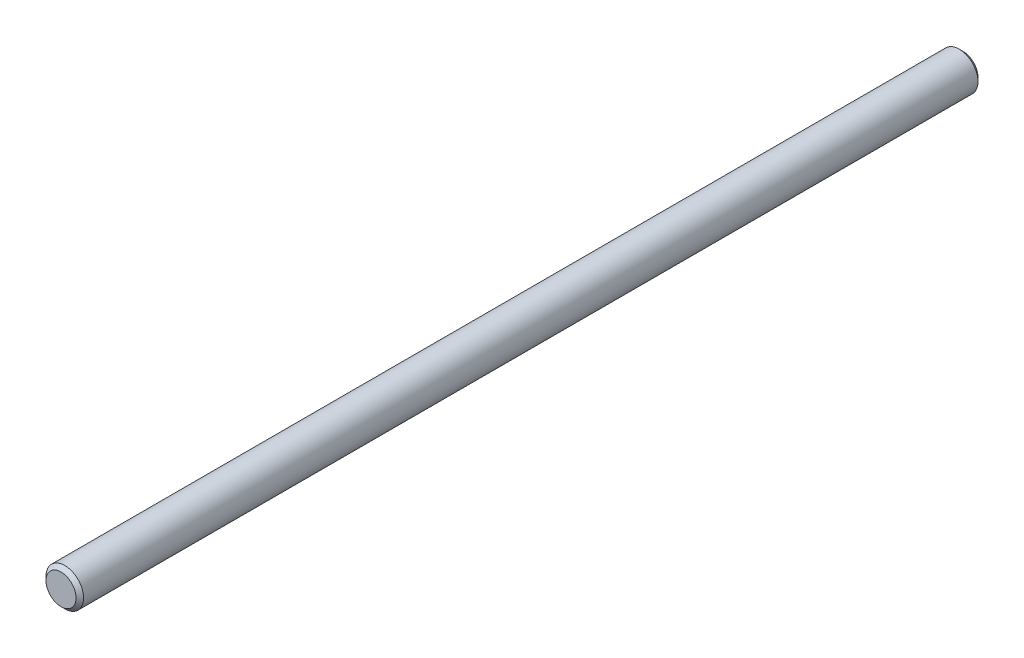
from build123d import *

# Parameters (mm, degrees)
SKETCH1_R      = 6.35
EXTRUDE1_DEPTH = 152.4
CHAMFER1_SIZE  = 1.27


with BuildPart() as part:
    # Sketch1 → Extrude1 (new body, symmetric)
    with BuildSketch(Plane.XY):
        Circle(SKETCH1_R)
    extrude(amount=EXTRUDE1_DEPTH, both=True)

    # Chamfer1
    chamfer1_edges = [part.edges().sort_by_distance(p)[0] for p in [
        (-6.35, 0, -152.4),
        (-6.35, 0, 152.4),
    ]]
    chamfer(chamfer1_edges, length=CHAMFER1_SIZE)


solid = part.part
